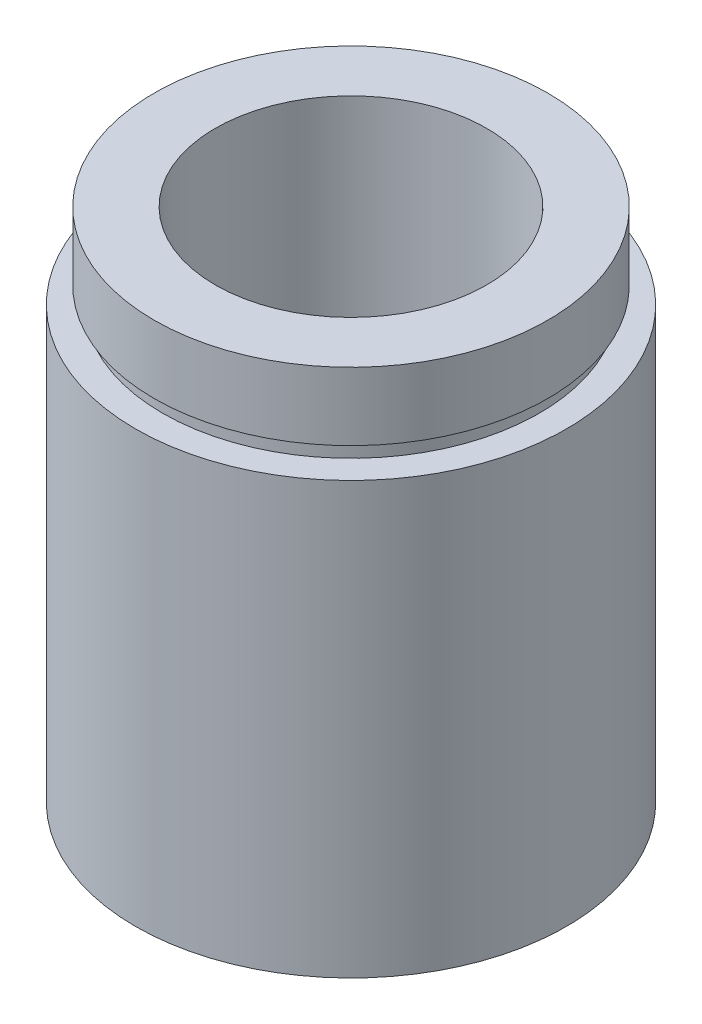
from build123d import *


with BuildPart() as part:
    # 草图1 → 旋转1 (revolve)
    with BuildSketch(Plane.XY, mode=Mode.PRIVATE) as revolve_1_sk:
        Polygon((11.1, 0), (11.1, 4.5), (11.7, 4.5), (11.7, 5.5), (8, 5.5), (8, 30.4), (11.6, 30.4), (11.6, 26.4), (11.1, 26.4), (11.1, 25.4), (12.7, 25.4), (12.7, 0), align=None)
    revolve(revolve_1_sk.sketch.rotate(Axis((0, 161.376166943, 0), (0, -1, 0)), 90), axis=Axis((0, 161.376166943, 0), (0, -1, 0)))  # turned: the seam where the file's is


solid = part.part
